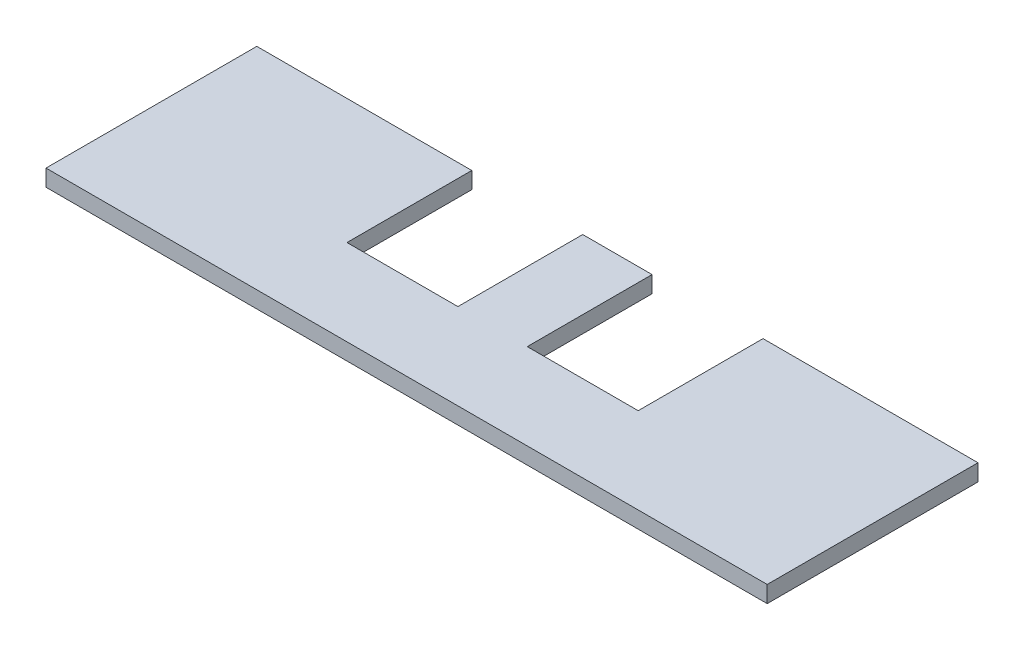
from build123d import *

# Parameters (mm, degrees)
SKETCH1_W               = 130
SKETCH1_H               = 120
BOSS_EXTRUDE1_DEPTH     = 3
CUT_EXTRUDE1_START      = -4
SKETCH2_W               = 20
SKETCH2_H               = 89
CUT_EXTRUDE1_DEPTH      = 5
CUT_EXTRUDE2_START      = -4
SKETCH3_R               = 1.6
CUT_EXTRUDE2_DEPTH      = 5
SKETCH4_W               = 130
SKETCH4_H               = 82
CUT_EXTRUDE3_DEPTH      = 1
CUT_EXTRUDE3_DEPTH_BACK = 4


with BuildPart() as part:
    # Sketch1 → Boss-Extrude1 (new body)
    with BuildSketch(Plane(origin=(0, 0, 0), x_dir=(1, 0, 0), z_dir=(0, 1, 0))):
        Rectangle(SKETCH1_W, SKETCH1_H)
    extrude(amount=BOSS_EXTRUDE1_DEPTH)

    # Sketch2 → Cut-Extrude1 (cut)
    with BuildSketch(Plane(origin=(0, 3, 0), x_dir=(1, 0, 0), z_dir=(0, 1, 0)).offset(CUT_EXTRUDE1_START)):
        with Locations((-16.25, 0)):
            Rectangle(SKETCH2_W, SKETCH2_H)
    cut_extrude1 = extrude(amount=CUT_EXTRUDE1_DEPTH, mode=Mode.SUBTRACT)

    # Mirror1: Cut-Extrude1 across plane
    add(cut_extrude1.mirror(Plane(origin=(0, 0, 0), x_dir=(0, 0, 1), z_dir=(1, 0, 0))), mode=Mode.SUBTRACT)

    # Sketch3 → Cut-Extrude2 (cut)
    with BuildSketch(Plane(origin=(0, 3, 0), x_dir=(1, 0, 0), z_dir=(0, 1, 0)).offset(CUT_EXTRUDE2_START)):
        with Locations((44.5, 0)):
            Circle(SKETCH3_R)
    cut_extrude2 = extrude(amount=CUT_EXTRUDE2_DEPTH, mode=Mode.SUBTRACT)

    # Mirror2: Cut-Extrude2 across plane
    add(cut_extrude2.mirror(Plane(origin=(0, 0, 0), x_dir=(0, 0, 1), z_dir=(1, 0, 0))), mode=Mode.SUBTRACT)

    # Sketch4 → Cut-Extrude3 (cut, two sides)
    with BuildSketch(Plane(origin=(0, 3, 0), x_dir=(1, 0, 0), z_dir=(0, 1, 0))) as cut_extrude3_sk:
        with Locations((0, 19)):
            Rectangle(SKETCH4_W, SKETCH4_H)
    extrude(amount=CUT_EXTRUDE3_DEPTH, mode=Mode.SUBTRACT)
    extrude(cut_extrude3_sk.sketch, amount=-CUT_EXTRUDE3_DEPTH_BACK, mode=Mode.SUBTRACT)


solid = part.part
